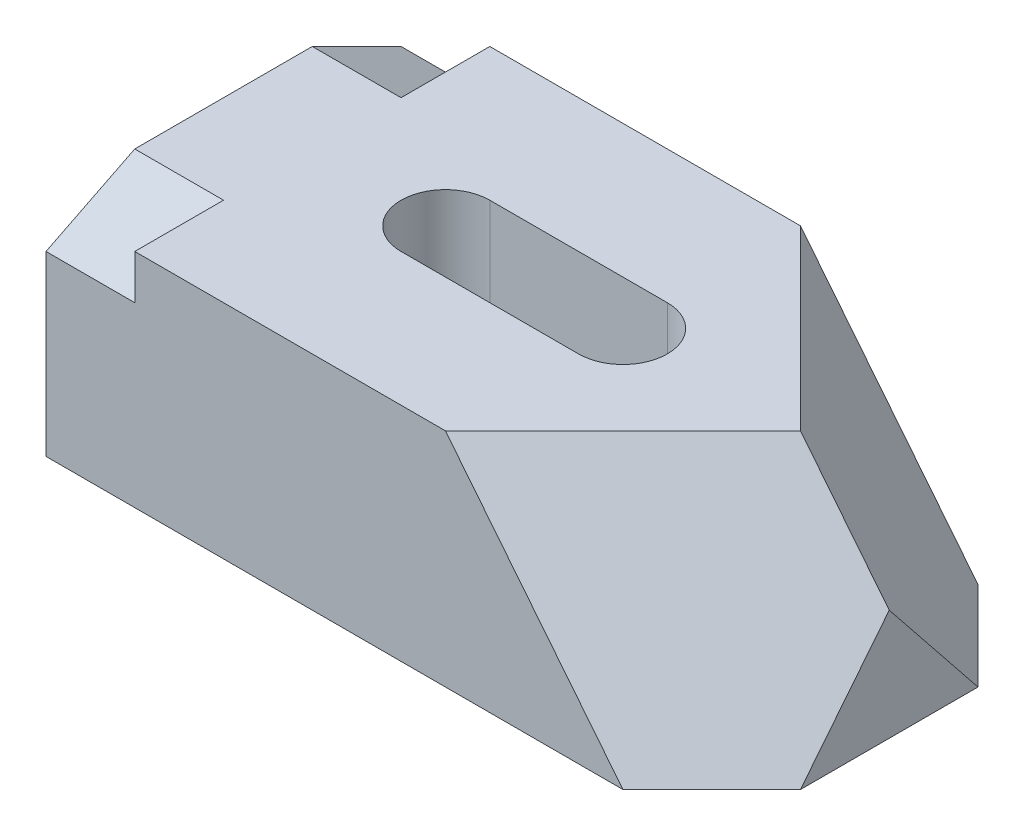
from build123d import *

# Parameters (mm, degrees)
SKETCH1_W           = 75
SKETCH1_H           = 40
BOSS_EXTRUDE1_DEPTH = 25
SKETCH5_W           = 56.924134656
SKETCH5_H           = 49.860042304
CUT_EXTRUDE1_DEPTH  = 19.463723647
SKETCH9_W           = 66.205259198
SKETCH9_H           = 57.927204101
CUT_EXTRUDE4_DEPTH  = 19.463723647
CUT_EXTRUDE5_DEPTH  = 10
CUT_EXTRUDE6_DEPTH  = 10
SKETCH12_R          = 5
CUT_EXTRUDE7_DEPTH  = 26
SKETCH13_R          = 5
CUT_EXTRUDE8_DEPTH  = 26
SKETCH14_W          = 20
SKETCH14_H          = 10
CUT_EXTRUDE9_DEPTH  = 26


with BuildPart() as part:
    # Sketch1 → Boss-Extrude1 (new body)
    with BuildSketch(Plane(origin=(0, 0, 0), x_dir=(1, 0, 0), z_dir=(0, 1, 0))):
        with Locations((37.5, 20)):
            Rectangle(SKETCH1_W, SKETCH1_H)
    extrude(amount=BOSS_EXTRUDE1_DEPTH)

    # Sketch5 → Cut-Extrude1 (cut, through all)
    with BuildSketch(Plane(origin=(24.621212121, 19.696969697, 24.621212121), x_dir=(-0.48059153, -0.384473224, 0.788170109), z_dir=(-0.615457455, -0.492365964, -0.615457455))):
        with Locations((-56.377268539, -29.25842023)):
            Rectangle(SKETCH5_W, SKETCH5_H)
    extrude(amount=-CUT_EXTRUDE1_DEPTH, mode=Mode.SUBTRACT)

    # Sketch9 → Cut-Extrude4 (cut, through all)
    with BuildSketch(Plane(origin=(39.772727273, 31.818181818, -39.772727273), x_dir=(-0.48059153, -0.384473224, -0.788170109), z_dir=(0.615457455, 0.492365964, -0.615457455))):
        with Locations((-25.664759868, -34.253534267)):
            Rectangle(SKETCH9_W, SKETCH9_H)
    extrude(amount=CUT_EXTRUDE4_DEPTH, mode=Mode.SUBTRACT)

    # Sketch10 → Cut-Extrude5 (cut)
    with BuildSketch(Plane.ZY):
        Polygon((-10, 25), (0, 20), (0, 25), align=None)
    extrude(amount=-CUT_EXTRUDE5_DEPTH, mode=Mode.SUBTRACT)

    # Sketch11 → Cut-Extrude6 (cut)
    with BuildSketch(Plane.ZY):
        Polygon((-40, 20), (-30, 25), (-40, 25), align=None)
    extrude(amount=-CUT_EXTRUDE6_DEPTH, mode=Mode.SUBTRACT)

    # Sketch12 → Cut-Extrude7 (cut, through all)
    with BuildSketch(Plane(origin=(0, 25, 0), x_dir=(1, 0, 0), z_dir=(0, 1, 0))):
        with Locations((25, 20)):
            Circle(SKETCH12_R)
    extrude(amount=-CUT_EXTRUDE7_DEPTH, mode=Mode.SUBTRACT)

    # Sketch13 → Cut-Extrude8 (cut, through all)
    with BuildSketch(Plane(origin=(0, 25, 0), x_dir=(1, 0, 0), z_dir=(0, 1, 0))):
        with Locations((45, 20)):
            Circle(SKETCH13_R)
    extrude(amount=-CUT_EXTRUDE8_DEPTH, mode=Mode.SUBTRACT)

    # Sketch14 → Cut-Extrude9 (cut, through all)
    with BuildSketch(Plane(origin=(0, 25, 0), x_dir=(1, 0, 0), z_dir=(0, 1, 0))):
        with Locations((35, 20)):
            Rectangle(SKETCH14_W, SKETCH14_H)
    extrude(amount=-CUT_EXTRUDE9_DEPTH, mode=Mode.SUBTRACT)


solid = part.part
